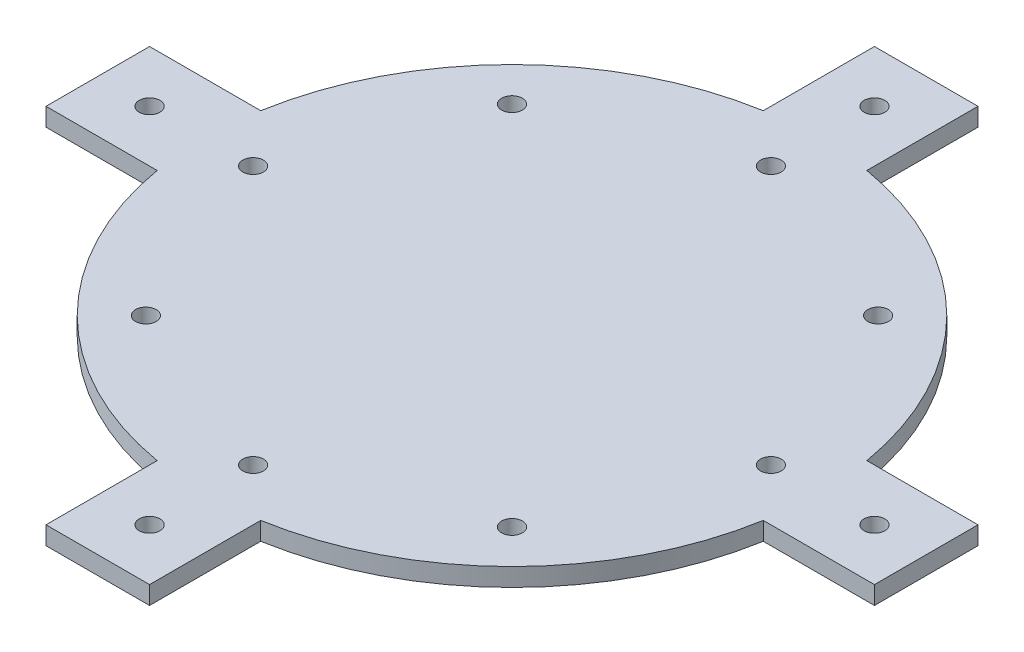
from build123d import *

# Parameters (mm, degrees)
SALIENTE_EXTRUIR1_DEPTH = 3.5
CROQUIS2_R              = 2
CORTAR_EXTRUIR1_DEPTH   = 3.5
MATRIZC1_COUNT          = 8
CORTAR_EXTRUIR2_REACH   = 5.5
CROQUIS4_R              = 2


with BuildPart() as part:
    # Croquis1 → Saliente-Extruir1 (new body)
    with BuildSketch(Plane(origin=(0, 0, 0), x_dir=(1, 0, 0), z_dir=(0, 1, 0))):
        with BuildLine():
            Line((-10, -58.530413525), (-10, -80))
            Line((-10, -80), (10, -80))
            Line((10, -80), (10, -58.530413525))
            ThreePointArc((10, -58.530413525), (41.986958138, -41.986958138), (58.530413525, -10))
            Line((58.530413525, -10), (80, -10))
            Line((80, -10), (80, 10))
            Line((80, 10), (58.530413525, 10))
            ThreePointArc((58.530413525, 10), (41.986958138, 41.986958138), (10, 58.530413525))
            Line((10, 58.530413525), (10, 80))
            Line((10, 80), (-10, 80))
            Line((-10, 80), (-10, 58.530413525))
            ThreePointArc((-10, 58.530413525), (-41.986958138, 41.986958138), (-58.530413525, 10))
            Line((-58.530413525, 10), (-80, 10))
            Line((-80, 10), (-80, -10))
            Line((-80, -10), (-58.530413525, -10))
            ThreePointArc((-58.530413525, -10), (-41.986958138, -41.986958138), (-10, -58.530413525))
        make_face()
    extrude(amount=SALIENTE_EXTRUIR1_DEPTH)

    # Croquis2 → Cortar-Extruir1 (cut)
    with BuildSketch(Plane(origin=(0, 3.5, 0), x_dir=(1, 0, 0), z_dir=(0, 1, 0))):
        with Locations((0, 50)):
            Circle(CROQUIS2_R)
    cortar_extruir1 = extrude(amount=-CORTAR_EXTRUIR1_DEPTH, mode=Mode.SUBTRACT)

    # MatrizC1: Cortar-Extruir1 ×8 about axis
    matrizc1_axis = Axis((0, 0, 0), (0, 1, 0))
    for i in range(1, MATRIZC1_COUNT):
        add(cortar_extruir1.rotate(matrizc1_axis, i * 360 / MATRIZC1_COUNT), mode=Mode.SUBTRACT)

    # Croquis4 → Cortar-Extruir2 (cut, up to next)
    with BuildSketch(Plane(origin=(0, 3.5, 0), x_dir=(1, 0, 0), z_dir=(0, 1, 0)), mode=Mode.PRIVATE) as cortar_extruir2_sk1:
        with Locations((0, 70)):
            Circle(CROQUIS4_R)
    cortar_extruir2_tool1 = extrude(cortar_extruir2_sk1.sketch, amount=-CORTAR_EXTRUIR2_REACH, mode=Mode.PRIVATE) & part.part
    add(cortar_extruir2_tool1.solids().sort_by_distance((0, 3.5, -70))[0], mode=Mode.SUBTRACT)
    # Croquis4 → Cortar-Extruir2 (cut, up to next)
    with BuildSketch(Plane(origin=(0, 3.5, 0), x_dir=(1, 0, 0), z_dir=(0, 1, 0)), mode=Mode.PRIVATE) as cortar_extruir2_sk2:
        with Locations((70, 0)):
            Circle(CROQUIS4_R)
    cortar_extruir2_tool2 = extrude(cortar_extruir2_sk2.sketch, amount=-CORTAR_EXTRUIR2_REACH, mode=Mode.PRIVATE) & part.part
    add(cortar_extruir2_tool2.solids().sort_by_distance((70, 3.5, 0))[0], mode=Mode.SUBTRACT)
    # Croquis4 → Cortar-Extruir2 (cut, up to next)
    with BuildSketch(Plane(origin=(0, 3.5, 0), x_dir=(1, 0, 0), z_dir=(0, 1, 0)), mode=Mode.PRIVATE) as cortar_extruir2_sk3:
        with Locations((0, -70)):
            Circle(CROQUIS4_R)
    cortar_extruir2_tool3 = extrude(cortar_extruir2_sk3.sketch, amount=-CORTAR_EXTRUIR2_REACH, mode=Mode.PRIVATE) & part.part
    add(cortar_extruir2_tool3.solids().sort_by_distance((0, 3.5, 70))[0], mode=Mode.SUBTRACT)
    # Croquis4 → Cortar-Extruir2 (cut, up to next)
    with BuildSketch(Plane(origin=(0, 3.5, 0), x_dir=(1, 0, 0), z_dir=(0, 1, 0)), mode=Mode.PRIVATE) as cortar_extruir2_sk4:
        with Locations((-70, 0)):
            Circle(CROQUIS4_R)
    cortar_extruir2_tool4 = extrude(cortar_extruir2_sk4.sketch, amount=-CORTAR_EXTRUIR2_REACH, mode=Mode.PRIVATE) & part.part
    add(cortar_extruir2_tool4.solids().sort_by_distance((-70, 3.5, 0))[0], mode=Mode.SUBTRACT)


solid = part.part
